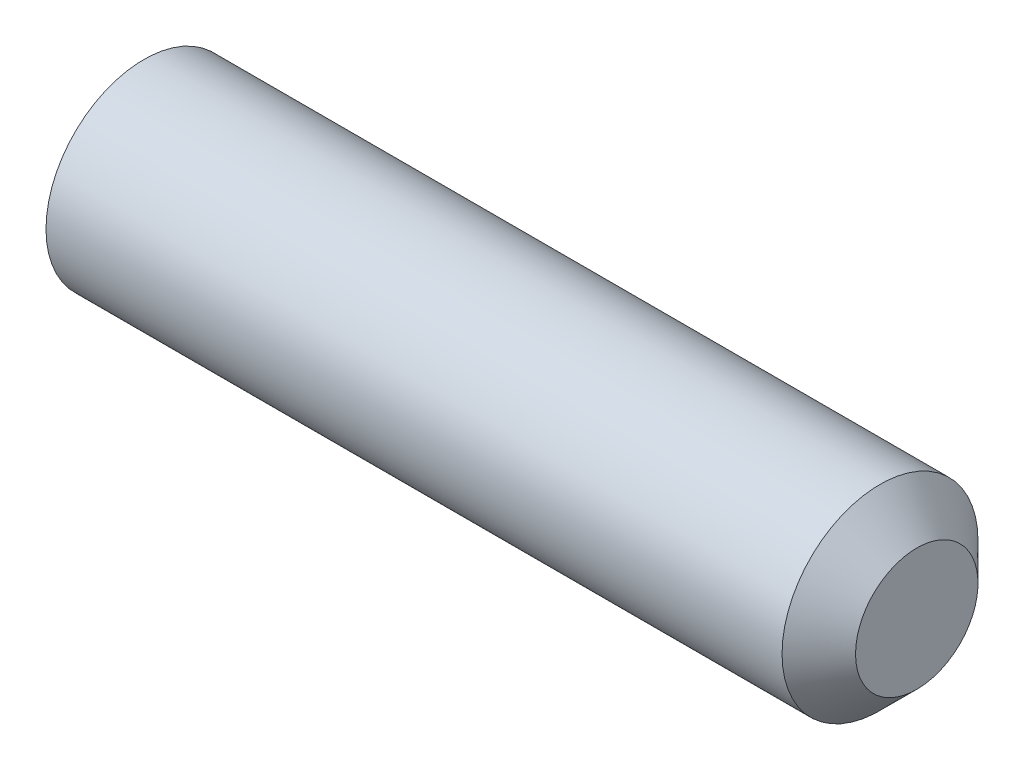
from build123d import *

# Parameters (mm, degrees)
HEX_2_DEPTH = 2.5


with BuildPart() as part:
    # BodySke → BaseBody (revolve)
    with BuildSketch(Plane.XY, mode=Mode.PRIVATE) as basebody_sk:
        Polygon((0, 0), (0, 1.61), (0.225166605, 2), (15.25, 2), (16, 1.25), (16, 0), align=None)
    revolve(basebody_sk.sketch.rotate(Axis((-12.7, 0, 0), (1, 0, 0)), 90), axis=Axis((-12.7, 0, 0), (1, 0, 0)))  # turned: the seam where the file's is

    # Sketch2 → Hex 2 (cut)
    with BuildSketch(Plane.ZY):
        Polygon((0.577350269, 1), (-0.577350269, 1), (-1.154700538, 0), (-0.577350269, -1), (0.577350269, -1), (1.154700538, 0), align=None)
    extrude(amount=-HEX_2_DEPTH, mode=Mode.SUBTRACT)


solid = part.part
